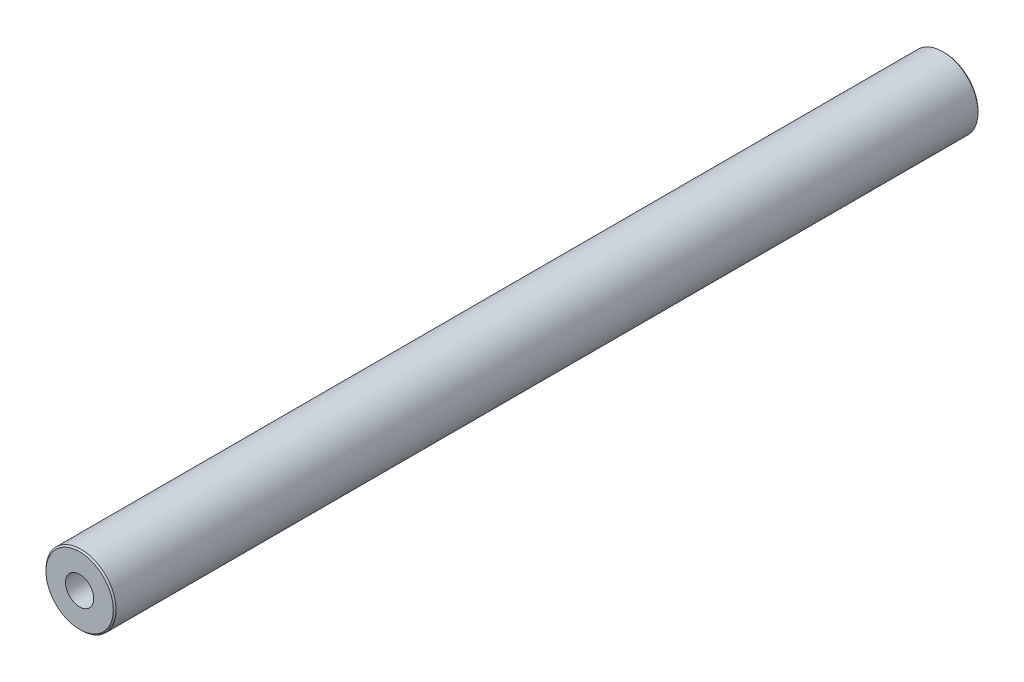
from build123d import *

# Parameters (mm, degrees)
SKETCH1_R                   = 6.35
BOSS_EXTRUDE1_DEPTH         = 78.2574
F_1_4_20_TAPPED_HOLE1_D     = 5.1054
F_1_4_20_TAPPED_HOLE1_DEPTH = 40
F_1_4_20_TAPPED_HOLE1_TIP   = 1.533816902
F_1_4_20_TAPPED_HOLE2_D     = 5.1054
F_1_4_20_TAPPED_HOLE2_DEPTH = 40
F_1_4_20_TAPPED_HOLE2_TIP   = 1.533816902
CHAMFER1_SIZE               = 0.254


with BuildPart() as part:
    # Sketch1 → Boss-Extrude1 (new body, symmetric)
    with BuildSketch(Plane.XY):
        Circle(SKETCH1_R)
    extrude(amount=BOSS_EXTRUDE1_DEPTH, both=True)

    # 1/4-20 Tapped Hole1
    with Locations(Plane.XY.offset(78.2574)):
        with Locations((0, 0)):
            Hole(F_1_4_20_TAPPED_HOLE1_D / 2, depth=F_1_4_20_TAPPED_HOLE1_DEPTH)
            with Locations((0, 0, -(F_1_4_20_TAPPED_HOLE1_DEPTH + F_1_4_20_TAPPED_HOLE1_TIP / 2))):  # 118° drill point
                Cone(0, F_1_4_20_TAPPED_HOLE1_D / 2, F_1_4_20_TAPPED_HOLE1_TIP, mode=Mode.SUBTRACT)

    # 1/4-20 Tapped Hole2
    with Locations(Plane(origin=(0, 0, -78.2574), x_dir=(-1, 0, 0), z_dir=(0, 0, -1))):
        with Locations((0, 0)):
            Hole(F_1_4_20_TAPPED_HOLE2_D / 2, depth=F_1_4_20_TAPPED_HOLE2_DEPTH)
            with Locations((0, 0, -(F_1_4_20_TAPPED_HOLE2_DEPTH + F_1_4_20_TAPPED_HOLE2_TIP / 2))):  # 118° drill point
                Cone(0, F_1_4_20_TAPPED_HOLE2_D / 2, F_1_4_20_TAPPED_HOLE2_TIP, mode=Mode.SUBTRACT)

    # Chamfer1
    chamfer1_edges = [part.edges().sort_by_distance(p)[0] for p in [
        (-6.35, 0, -78.2574),
        (-6.35, 0, 78.2574),
    ]]
    chamfer(chamfer1_edges, length=CHAMFER1_SIZE)


solid = part.part
